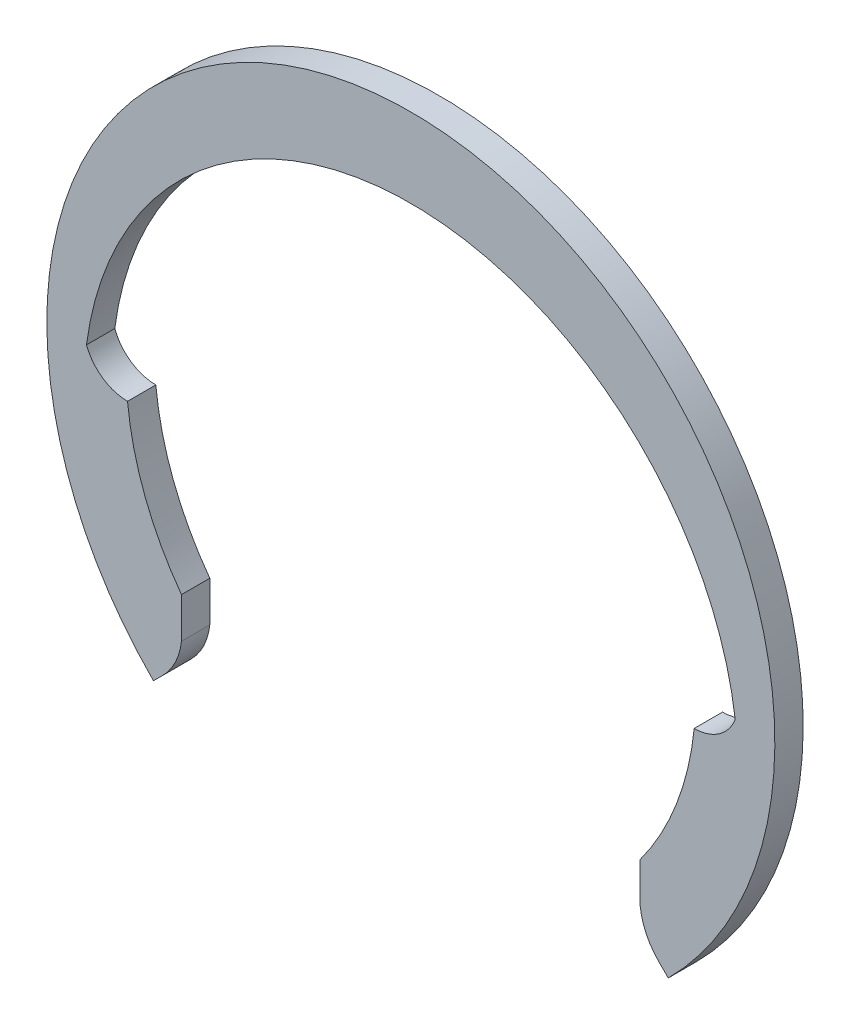
from build123d import *

# Parameters (mm, degrees)
BOSS_EXTRUDE1_DEPTH = 1.75


with BuildPart() as part:
    # Sketch2 → Boss-Extrude1 (new body)
    with BuildSketch(Plane.XY):
        with BuildLine():
            Line((-14.177490963, -12.927909418), (-14.177490963, -11.678327874))
            Line((-14.177490963, -11.678327874), (-14.177490963, -10.428746329))
            ThreePointArc((-14.177490963, -10.428746329), (-16.42858772, -6.313596877), (-17.512781047, -1.75))
            ThreePointArc((-17.512781047, -1.75), (-19.053882927, -1.270070223), (-20.05, 0))
            ThreePointArc((-20.05, 0), (0, 17.6), (20.05, 0))
            ThreePointArc((20.05, 0), (19.053882927, -1.270070223), (17.512781047, -1.75))
            ThreePointArc((17.512781047, -1.75), (16.42858772, -6.313596877), (14.177490963, -10.428746329))
            Line((14.177490963, -10.428746329), (14.177490963, -11.678327874))
            Line((14.177490963, -11.678327874), (14.177490963, -12.927909418))
            ThreePointArc((14.177490963, -12.927909418), (14.550059003, -14.228589562), (15.332432039, -15.332432039))
            Line((15.332432039, -15.332432039), (15.909902577, -15.909902577))
            ThreePointArc((15.909902577, -15.909902577), (0, 22.5), (-15.909902577, -15.909902577))
            Line((-15.909902577, -15.909902577), (-15.332432039, -15.332432039))
            ThreePointArc((-15.332432039, -15.332432039), (-14.550059003, -14.228589562), (-14.177490963, -12.927909418))
        make_face()
    extrude(amount=BOSS_EXTRUDE1_DEPTH)


solid = part.part
